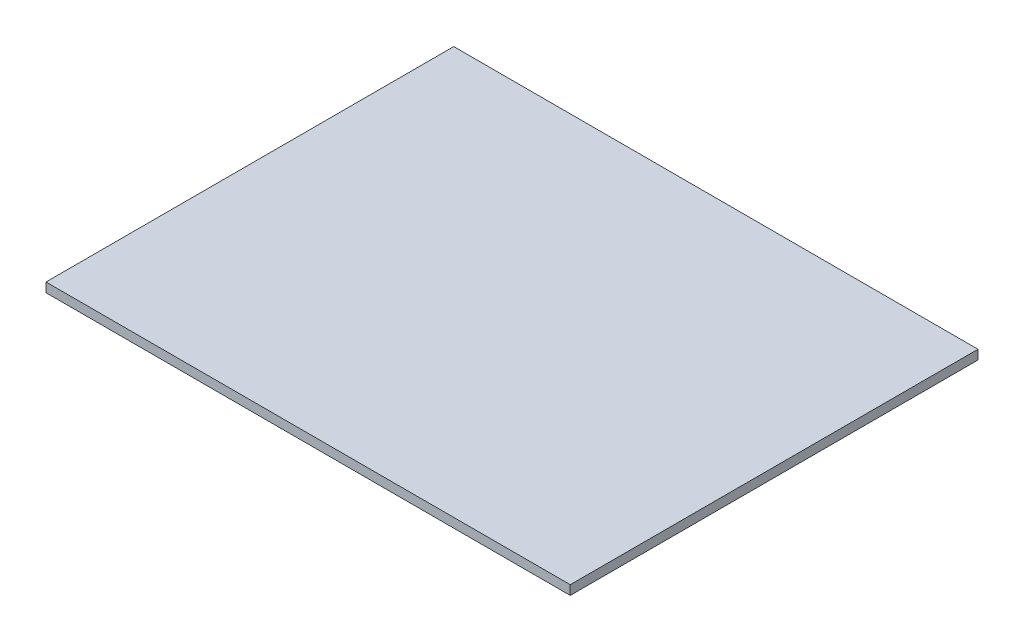
from build123d import *

# Parameters (mm, degrees)
SKETCH1_W           = 90
SKETCH1_H           = 70
BOSS_EXTRUDE1_DEPTH = 1.6


with BuildPart() as part:
    # Sketch1 → Boss-Extrude1 (new body)
    with BuildSketch(Plane(origin=(0, 0, 0), x_dir=(1, 0, 0), z_dir=(0, 1, 0))):
        with Locations((45, 35)):
            Rectangle(SKETCH1_W, SKETCH1_H)
    extrude(amount=BOSS_EXTRUDE1_DEPTH)


solid = part.part
